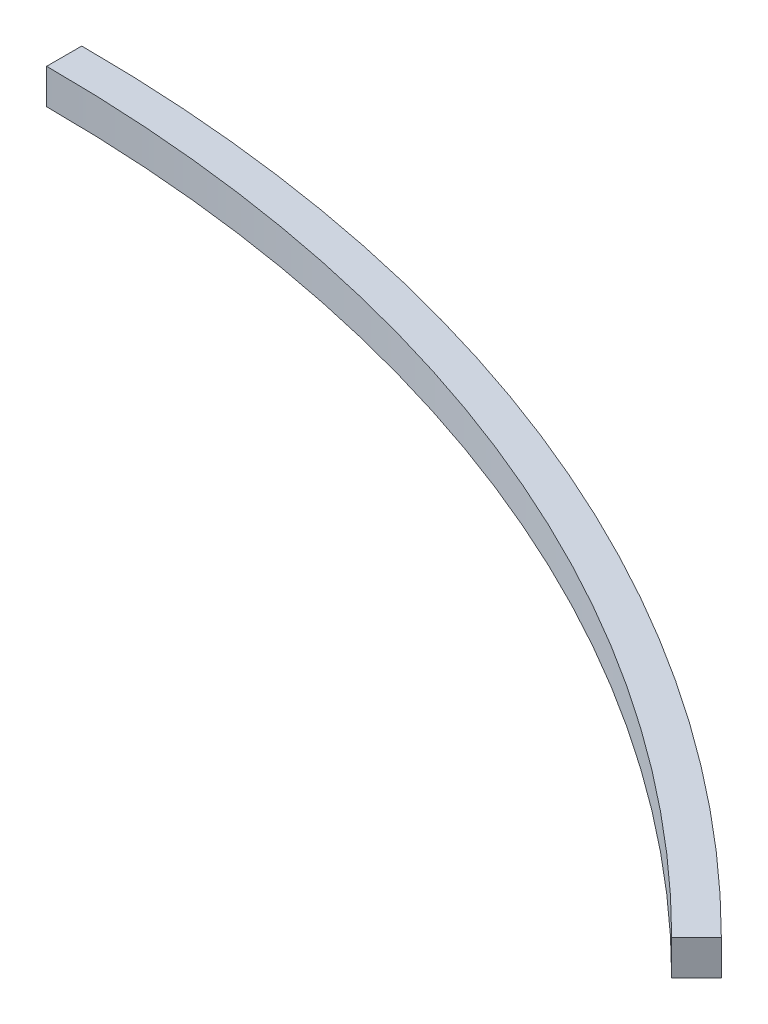
from build123d import *

# Parameters (mm, degrees)
BOSS_EXTRUDE1_DEPTH = 10


with BuildPart() as part:
    # Sketch1 → Boss-Extrude1 (new body)
    with BuildSketch(Plane(origin=(0, 0, 0), x_dir=(1, 0, 0), z_dir=(0, 1, 0))):
        with BuildLine():
            ThreePointArc((0, 440), (168.380710241, 406.506994305), (311.126983722, 311.126983722))
            Line((311.126983722, 311.126983722), (304.05591591, 304.05591591))
            ThreePointArc((304.05591591, 304.05591591), (164.553875917, 397.26819898), (0, 430))
            Line((0, 430), (0, 440))
        make_face()
    extrude(amount=BOSS_EXTRUDE1_DEPTH)


solid = part.part
